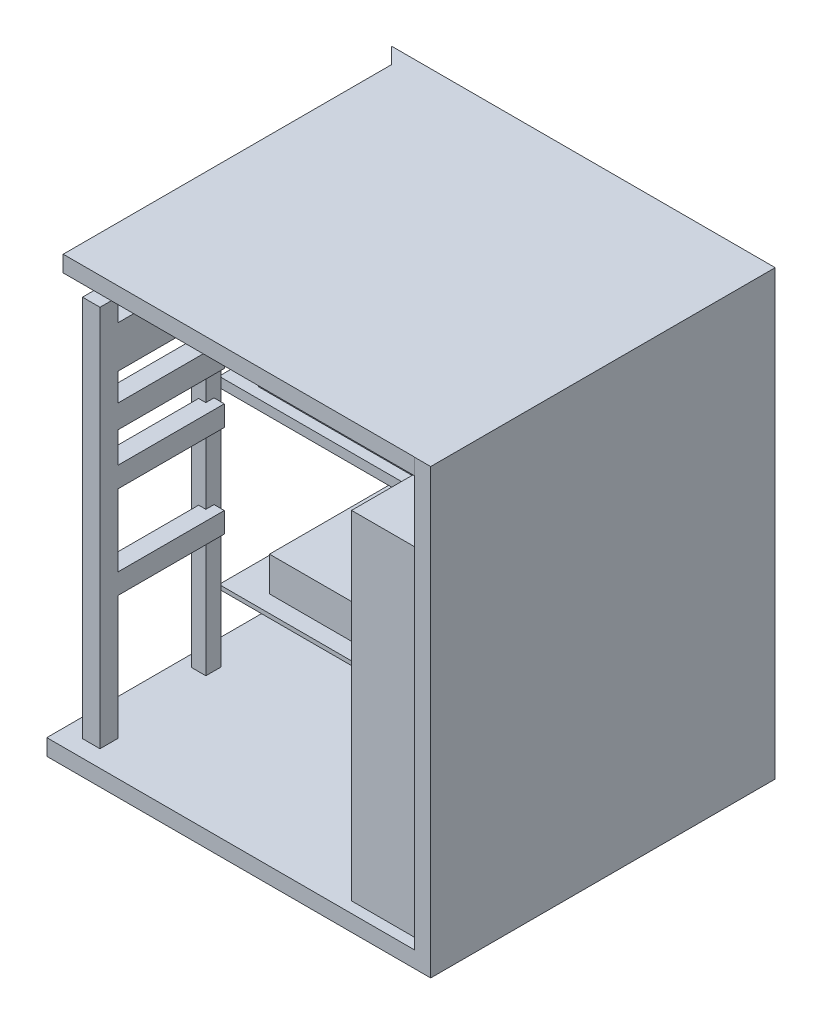
from build123d import *

# Parameters (mm, degrees)
SKETCH1_W            = 2377.44
SKETCH1_H            = 2133.6
BOSS_EXTRUDE1_DEPTH  = 100.584
BOSS_EXTRUDE2_DEPTH  = 2743.2
SKETCH3_W            = 2176.272
SKETCH3_H            = 100.584
BOSS_EXTRUDE3_DEPTH  = 2032.01016
SKETCH4_W            = 2176.272
SKETCH4_H            = 25.414103574
SKETCH4_H_2          = 60.640608873
BOSS_EXTRUDE4_DEPTH  = 1066.8
SKETCH5_W            = 810.743905069
SKETCH5_H            = 2094.827359662
BOSS_EXTRUDE5_DEPTH  = 457.2
SKETCH6_W            = 1997.703421867
SKETCH6_H            = 1001.430219192
BOSS_EXTRUDE6_DEPTH  = 213.36
SKETCH7_W            = 1969.099770792
SKETCH7_H            = 961.692694148
BOSS_EXTRUDE7_DEPTH  = 213.36
SKETCH8_W            = 266.86255044
SKETCH8_H            = 642.270503211
BOSS_EXTRUDE8_DEPTH  = 100.584
SKETCH9_W            = 335.117143437
SKETCH9_H            = 589.061250779
BOSS_EXTRUDE9_DEPTH  = 100.584
SKETCH10_W           = 89.586922485
SKETCH10_H           = 95.120149651
SKETCH10_W_2         = 108.315606024
SKETCH10_H_2         = 112.834603223
BOSS_EXTRUDE10_DEPTH = 2368.042
SKETCH11_W           = 108.315606024
SKETCH11_H           = 126.330231555
SKETCH11_H_2         = 126.865564389
SKETCH11_H_3         = 143.81666183
SKETCH11_H_4         = 260.020873713
BOSS_EXTRUDE11_DEPTH = 657.098


with BuildPart() as part:
    # Sketch1 → Boss-Extrude1 (new body)
    with BuildSketch(Plane(origin=(0, 0, 0), x_dir=(1, 0, 0), z_dir=(0, 1, 0))):
        with Locations((1188.72, 1066.8)):
            Rectangle(SKETCH1_W, SKETCH1_H)
    extrude(amount=BOSS_EXTRUDE1_DEPTH)

    # Sketch2 → Boss-Extrude2 (add)
    with BuildSketch(Plane(origin=(0, 0, 0), x_dir=(1, 0, 0), z_dir=(0, 1, 0))):
        Polygon((0, 2133.6), (100.584, 2133.6), (2377.44, 2133.6), (2377.44, 2033.016), (2377.44, 0), (2276.856, 0), (2276.856, 2033.016), (100.584, 2033.016), align=None)
    extrude(amount=BOSS_EXTRUDE2_DEPTH)

    # Sketch3 → Boss-Extrude3 (add)
    with BuildSketch(Plane.XY.offset(-2033.016)):
        with Locations((1188.72, 2692.908)):
            Rectangle(SKETCH3_W, SKETCH3_H)
    extrude(amount=BOSS_EXTRUDE3_DEPTH)

    # Sketch4 → Boss-Extrude4 (add)
    with BuildSketch(Plane.XY.offset(-2033.016)):
        with Locations((1188.72, 476.779733843)):
            Rectangle(SKETCH4_W, SKETCH4_H)
        with Locations((1188.72, 1575.975695564)):
            Rectangle(SKETCH4_W, SKETCH4_H_2)
    extrude(amount=BOSS_EXTRUDE4_DEPTH)

    # Sketch5 → Boss-Extrude5 (add)
    with BuildSketch(Plane.ZY.offset(-2276.856)):
        with Locations((-473.120217172, 1147.997679831)):
            Rectangle(SKETCH5_W, SKETCH5_H)
    extrude(amount=BOSS_EXTRUDE5_DEPTH)

    # Sketch6 → Boss-Extrude6 (add)
    with BuildSketch(Plane(origin=(0, 1606.296, 0), x_dir=(1, 0, 0), z_dir=(0, 1, 0))):
        with Locations((1278.004289067, 1532.300890404)):
            Rectangle(SKETCH6_W, SKETCH6_H)
    extrude(amount=BOSS_EXTRUDE6_DEPTH)

    # Sketch7 → Boss-Extrude7 (add)
    with BuildSketch(Plane(origin=(0, 489.48678563, 0), x_dir=(1, 0, 0), z_dir=(0, 1, 0))):
        with Locations((1292.306114604, 1552.169652926)):
            Rectangle(SKETCH7_W, SKETCH7_H)
    extrude(amount=BOSS_EXTRUDE7_DEPTH)

    # Sketch8 → Boss-Extrude8 (add)
    with BuildSketch(Plane(origin=(0, 1819.656, 0), x_dir=(1, 0, 0), z_dir=(0, 1, 0))):
        with Locations((1976.172529311, 1574.892629599)):
            Rectangle(SKETCH8_W, SKETCH8_H)
    extrude(amount=BOSS_EXTRUDE8_DEPTH)

    # Sketch9 → Boss-Extrude9 (add)
    with BuildSketch(Plane(origin=(0, 702.84678563, 0), x_dir=(1, 0, 0), z_dir=(0, 1, 0))):
        with Locations((1975.343586519, 1544.745806452)):
            Rectangle(SKETCH9_W, SKETCH9_H)
    extrude(amount=BOSS_EXTRUDE9_DEPTH)

    # Sketch10 → Boss-Extrude10 (add)
    with BuildSketch(Plane(origin=(0, 100.584, 0), x_dir=(1, 0, 0), z_dir=(0, 1, 0))):
        with Locations((116.124300093, 871.717601268)):
            Rectangle(SKETCH10_W, SKETCH10_H)
        with Locations((170.282103105, 161.329423399)):
            Rectangle(SKETCH10_W_2, SKETCH10_H_2)
    extrude(amount=BOSS_EXTRUDE10_DEPTH)

    # Sketch11 → Boss-Extrude11 (add)
    with BuildSketch(Plane(origin=(0, 0, -217.74672501), x_dir=(-1, 0, 0), z_dir=(0, 0, -1))):
        with Locations((-170.282103105, 930.200863925)):
            Rectangle(SKETCH11_W, SKETCH11_H)
        with Locations((-170.282103105, 1502.211041792)):
            Rectangle(SKETCH11_W, SKETCH11_H_2)
        with Locations((-170.282103105, 1827.31516865)):
            Rectangle(SKETCH11_W, SKETCH11_H_3)
        with Locations((-170.282103105, 2199.860048946)):
            Rectangle(SKETCH11_W, SKETCH11_H_4)
    extrude(amount=BOSS_EXTRUDE11_DEPTH)


solid = part.part
